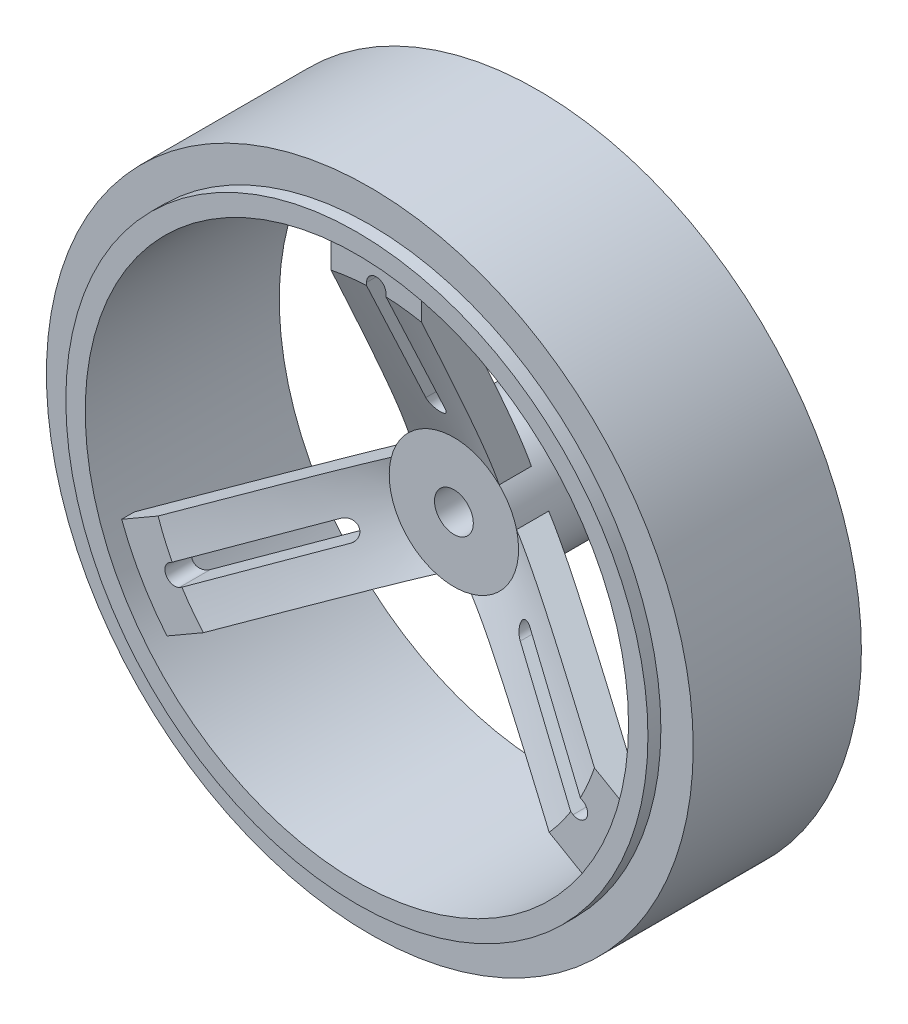
from build123d import *

# Parameters (mm, degrees)
SKETCH1_R           = 45
SKETCH1_R_2         = 42
BOSS_EXTRUDE1_DEPTH = 15
BOSS_EXTRUDE2_START = -15
SKETCH1_3_R         = 10
SKETCH1_3_R_2       = 3
BOSS_EXTRUDE2_DEPTH = 15
BOSS_EXTRUDE3_START = -5
SKETCH2_W           = 14
SKETCH2_H           = 37.310793113
BOSS_EXTRUDE3_DEPTH = 17
CIRPATTERN1_COUNT   = 3
SKETCH1_4_R         = 50
SKETCH1_4_R_2       = 45
BOSS_EXTRUDE4_DEPTH = 13


with BuildPart() as part:
    # Sketch1 → Boss-Extrude1 (new body, symmetric)
    with BuildSketch(Plane.XY):
        Circle(SKETCH1_R)
        Circle(SKETCH1_R_2, mode=Mode.SUBTRACT)
    extrude(amount=BOSS_EXTRUDE1_DEPTH, both=True)



with BuildPart() as body_2:
    # Sketch1_3 → Boss-Extrude2 (new body)
    with BuildSketch(Plane.XY.offset(BOSS_EXTRUDE2_START)):
        Circle(SKETCH1_3_R)
        Circle(SKETCH1_3_R_2, mode=Mode.SUBTRACT)
    extrude(amount=BOSS_EXTRUDE2_DEPTH)


with BuildPart() as part_1:
    add(part.part)

    add(body_2.part)  # Boss-Extrude3 merges body 2
    # Sketch2 → Boss-Extrude3 (add)
    with BuildSketch(Plane.XY.offset(BOSS_EXTRUDE3_START)):
        with Locations((0, 25.796824986)):
            Rectangle(SKETCH2_W, SKETCH2_H)
        with BuildLine():
            Line((1.5, 36), (1.5, 16))
            ThreePointArc((1.5, 16), (0, 14.5), (-1.5, 16))
            Line((-1.5, 16), (-1.5, 36))
            ThreePointArc((-1.5, 36), (0, 37.5), (1.5, 36))
        make_face(mode=Mode.SUBTRACT)
    boss_extrude3 = extrude(amount=BOSS_EXTRUDE3_DEPTH)

    # CirPattern1: Boss-Extrude3 ×3 about axis
    cirpattern1_axis = Axis((0, 0, 0), (0, 0, 1))
    for i in range(1, CIRPATTERN1_COUNT):
        add(boss_extrude3.rotate(cirpattern1_axis, i * 360 / CIRPATTERN1_COUNT))

    # Sketch3 → Cut-Revolve1 (revolve, cut)
    with BuildSketch(Plane(origin=(0, 0, 0), x_dir=(0, 0, -1), z_dir=(1, 0, 0))):
        Polygon((0, 0), (0, -10), (-15, -42), (-15, 0), align=None)
        Polygon((4.969855419, -10), (15, -10), (15, -42), (-10.030144581, -42), align=None)
    revolve(axis=Axis((0, 0, 0), (0, 0, 1)), mode=Mode.SUBTRACT)

    # Sketch1_4 → Boss-Extrude4 (add, symmetric)
    with BuildSketch(Plane.XY):
        Circle(SKETCH1_4_R)
        Circle(SKETCH1_4_R_2, mode=Mode.SUBTRACT)
    extrude(amount=BOSS_EXTRUDE4_DEPTH, both=True)


solid = part_1.part
